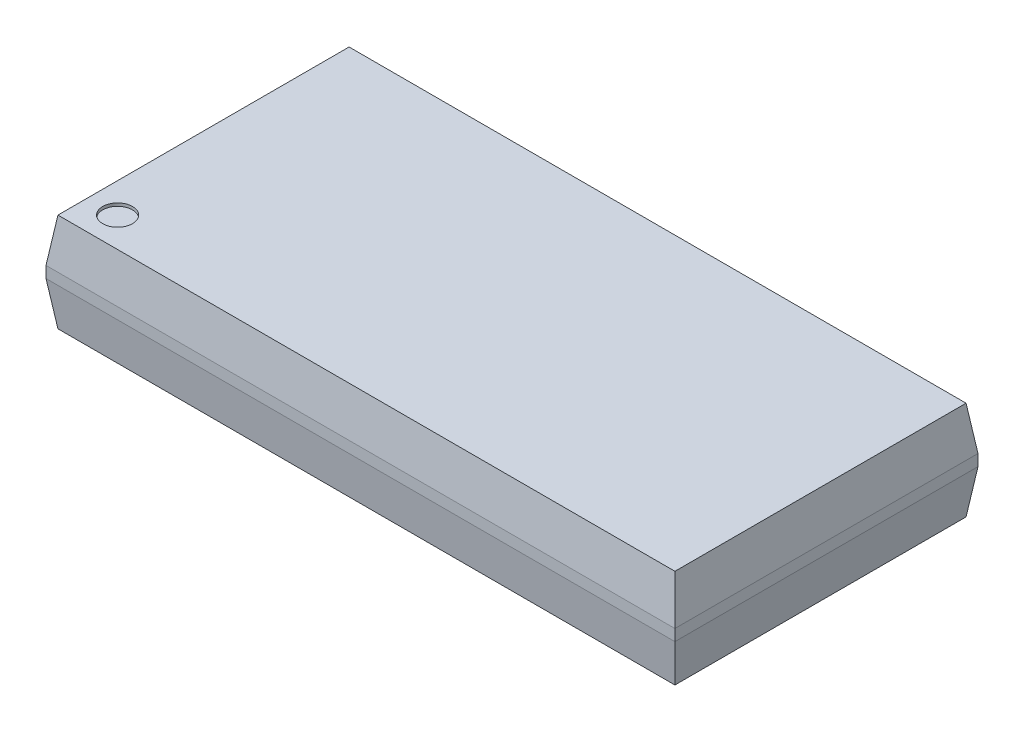
from build123d import *

# Parameters (mm, degrees)
SKETCH1_W            = 21.082
SKETCH1_H            = 10.16
BOSS_EXTRUDE1_DEPTH  = 1.651
CUT_EXTRUDE1_DEPTH   = 22.082
MIRROR2_COPY_1_DEPTH = 22.082
CUT_EXTRUDE2_DEPTH   = 11.16
MIRROR4_COPY_1_DEPTH = 11.16
SKETCH4_R            = 0.5
CUT_EXTRUDE3_DEPTH   = 0.1


with BuildPart() as part:
    # Sketch1 → Boss-Extrude1 (new body, symmetric)
    with BuildSketch(Plane(origin=(0, 0, 0), x_dir=(1, 0, 0), z_dir=(0, 1, 0))):
        Rectangle(SKETCH1_W, SKETCH1_H)
    extrude(amount=BOSS_EXTRUDE1_DEPTH, both=True)

    # Sketch2 → Cut-Extrude1 (cut, through all)
    with BuildSketch(Plane(origin=(10.541, 0, 0), x_dir=(0, 0, -1), z_dir=(1, 0, 0))):
        Polygon((-5.08, 1.651), (-4.88, 1.651), (-5.08, 0.1905), align=None)
    cut_extrude1 = extrude(amount=-CUT_EXTRUDE1_DEPTH, mode=Mode.SUBTRACT)

    # Mirror1: Cut-Extrude1 across plane
    add(cut_extrude1.mirror(Plane.XY), mode=Mode.SUBTRACT)

    # Mirror2: Cut-Extrude1 across plane
    add(cut_extrude1.mirror(Plane.ZX), mode=Mode.SUBTRACT)

    # Mirror2 copy 1 sketch → Mirror2 copy 1 (cut, through all)
    with BuildSketch(Plane(origin=(10.541, 0, 0), x_dir=(0, 0, 1), z_dir=(1, 0, 0))):
        Polygon((-5.08, 1.651), (-4.88, 1.651), (-5.08, 0.1905), align=None)
    extrude(amount=-MIRROR2_COPY_1_DEPTH, mode=Mode.SUBTRACT)

    # Sketch3 → Cut-Extrude2 (cut, through all)
    with BuildSketch(Plane.XY.offset(5.08)):
        Polygon((10.541, 0.1905), (10.541, 1.651), (10.341, 1.651), align=None)
    cut_extrude2 = extrude(amount=-CUT_EXTRUDE2_DEPTH, mode=Mode.SUBTRACT)

    # Mirror3: Cut-Extrude2 across plane
    add(cut_extrude2.mirror(Plane.ZX), mode=Mode.SUBTRACT)

    # Mirror4: Cut-Extrude2 across plane
    add(cut_extrude2.mirror(Plane(origin=(0, 0, 0), x_dir=(0, 0, 1), z_dir=(1, 0, 0))), mode=Mode.SUBTRACT)

    # Mirror4 copy 1 sketch → Mirror4 copy 1 (cut, through all)
    with BuildSketch(Plane(origin=(0, 0, 5.08), x_dir=(-1, 0, 0), z_dir=(0, 0, 1))):
        Polygon((10.541, 0.1905), (10.541, 1.651), (10.341, 1.651), align=None)
    extrude(amount=-MIRROR4_COPY_1_DEPTH, mode=Mode.SUBTRACT)

    # Sketch4 → Cut-Extrude3 (cut)
    with BuildSketch(Plane(origin=(0, 1.651, 0), x_dir=(1, 0, 0), z_dir=(0, 1, 0))):
        with Locations((-9.341, -3.88)):
            Circle(SKETCH4_R)
    extrude(amount=-CUT_EXTRUDE3_DEPTH, mode=Mode.SUBTRACT)


solid = part.part
